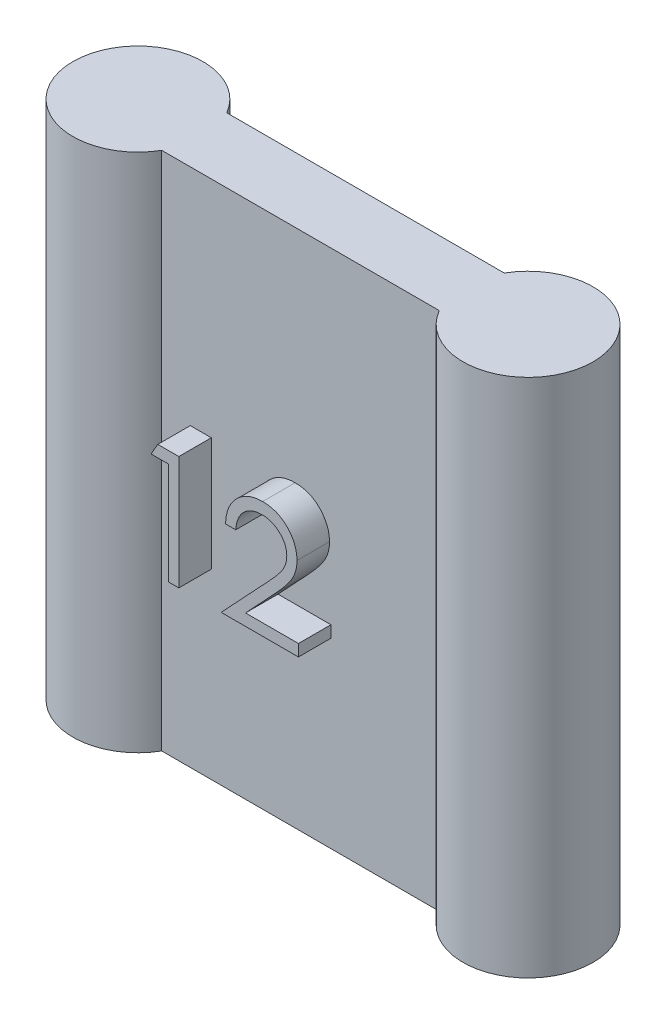
from build123d import *

# Parameters (mm, degrees)
SKETCH1_W           = 12
SKETCH1_H           = 16
BOSS_EXTRUDE1_DEPTH = 2
SKETCH4_R           = 2
BOSS_EXTRUDE4_DEPTH = 16
BOSS_EXTRUDE5_DEPTH = 1


with BuildPart() as part:
    # Sketch1 → Boss-Extrude1 (new body)
    with BuildSketch(Plane.XY):
        Rectangle(SKETCH1_W, SKETCH1_H)
    extrude(amount=BOSS_EXTRUDE1_DEPTH)

    # Sketch4 → Boss-Extrude4 (add)
    with BuildSketch(Plane.XZ.offset(8)):
        with Locations((-6, 1)):
            Circle(SKETCH4_R)
        with Locations((6, 1)):
            Circle(SKETCH4_R)
    extrude(amount=-BOSS_EXTRUDE4_DEPTH)

    # Sketch5 → Boss-Extrude5 (add)
    with BuildSketch(Plane.XY.offset(2)):
        Polygon((-3.389443583, 1.106736913), (-2.742308167, 1.106736913), (-2.742308167, -2.393263087), (-3.056410731, -2.393263087), (-3.056410731, 0.747762554), (-3.594872269, 0.747762554), align=None)
        with BuildLine():
            Line((-0.992308167, 0.029813837), (-1.306410731, 0.029813837))
            add(Edge.make_bspline(
                [(-1.306410731, 0.029813837), (-1.304363578, 0.071484724), (-1.300343024, 0.153325239), (-1.281514735, 0.272649145), (-1.254573857, 0.386703944), (-1.216482403, 0.494573858), (-1.169176126, 0.597212665), (-1.112446098, 0.694212681), (-1.045252248, 0.78520387), (-0.969045514, 0.869342713), (-0.886276875, 0.946530284), (-0.796970935, 1.013185526), (-0.703125908, 1.069503198), (-0.605026509, 1.11658444), (-0.501565945, 1.151924286), (-0.393683087, 1.178145925), (-0.280903951, 1.193922271), (-0.204063929, 1.195618057), (-0.164984449, 1.196480503)],
                knots=[0, 0, 0, 0, 0.000125083, 0.00024566, 0.000361805, 0.000476223, 0.000588214, 0.000700404, 0.000812728, 0.00092691, 0.001040529, 0.001151727, 0.001260545, 0.001368429, 0.001477521, 0.001587884, 0.001701119, 0.00181831, 0.00181831, 0.00181831, 0.00181831], degree=3))
            add(Edge.make_bspline(
                [(-0.164984449, 1.196480503), (-0.126606375, 1.195582047), (-0.05119483, 1.193816612), (0.058867184, 1.178655583), (0.163644479, 1.154909991), (0.262932245, 1.121594575), (0.35593831, 1.076810147), (0.443361354, 1.023012609), (0.526242165, 0.960792777), (0.600848949, 0.887538964), (0.669357028, 0.809336579), (0.728459283, 0.725848676), (0.779072447, 0.63961939), (0.821260127, 0.549991188), (0.852316266, 0.45612016), (0.875894474, 0.359372957), (0.889221887, 0.258748146), (0.891267311, 0.190641591), (0.892307218, 0.15601576)],
                knots=[0, 0, 0, 0, 0.000115089, 0.000226145, 0.000332614, 0.000437044, 0.000539592, 0.000641561, 0.000744629, 0.00084975, 0.000954621, 0.001056175, 0.001156101, 0.001254284, 0.001352726, 0.001452208, 0.001552655, 0.001656537, 0.001656537, 0.001656537, 0.001656537], degree=3))
            add(Edge.make_bspline(
                [(0.892307218, 0.15601576), (0.890613955, 0.107267925), (0.887257144, 0.010627711), (0.858542767, -0.131387151), (0.813696256, -0.26898057), (0.759698899, -0.379717873), (0.705226455, -0.468951366), (0.656138947, -0.542420071), (0.598674136, -0.62152554), (0.531995638, -0.706002877), (0.457482766, -0.796513782), (0.374460603, -0.893003578), (0.282337121, -0.994475347), (0.21767862, -1.063780949), (0.184174205, -1.099693375)],
                knots=[0, 0, 0, 0, 0.000146118, 0.000289672, 0.0004329, 0.00057934, 0.000657978, 0.000746456, 0.000844345, 0.000951219, 0.001069268, 0.00119604, 0.001333047, 0.001480391, 0.001480391, 0.001480391, 0.001480391], degree=3))
            Line((0.184174205, -1.099693375), (-0.691526917, -2.034288728))
            Line((-0.691526917, -2.034288728), (0.937179013, -2.034288728))
            Line((0.937179013, -2.034288728), (0.937179013, -2.393263087))
            Line((0.937179013, -2.393263087), (-1.441026116, -2.393263087))
            Line((-1.441026116, -2.393263087), (-0.083654321, -0.944745458))
            add(Edge.make_bspline(
                [(-0.083654321, -0.944745458), (-0.050606434, -0.910247152), (0.012871793, -0.843982965), (0.10265437, -0.747240005), (0.183293358, -0.657490464), (0.255310751, -0.574903916), (0.317144257, -0.498272348), (0.372016488, -0.430077645), (0.415982079, -0.367323194), (0.463697475, -0.29458258), (0.509911457, -0.205770263), (0.549623813, -0.097236574), (0.573838661, 0.014490679), (0.576743497, 0.089992716), (0.578204654, 0.127970888)],
                knots=[0, 0, 0, 0, 0.000143319, 0.000275286, 0.00039593, 0.000505287, 0.000603949, 0.000691331, 0.000767782, 0.00083371, 0.000952247, 0.001067137, 0.001179618, 0.001293462, 0.001293462, 0.001293462, 0.001293462], degree=3))
            add(Edge.make_bspline(
                [(0.578204654, 0.127970888), (0.577568911, 0.151852286), (0.576315985, 0.198917937), (0.565258288, 0.267923696), (0.548547782, 0.334488509), (0.524602524, 0.398817129), (0.492995784, 0.460262781), (0.454522404, 0.518900261), (0.41013234, 0.575589226), (0.358781071, 0.628742524), (0.302369551, 0.67742373), (0.242775302, 0.720547815), (0.179725197, 0.756586926), (0.113485075, 0.786130423), (0.044239606, 0.809305804), (-0.028145139, 0.825364384), (-0.103469156, 0.835446867), (-0.154902651, 0.836811039), (-0.18111025, 0.837506144)],
                knots=[0, 0, 0, 0, 7.16e-05, 0.00014111, 0.00020913, 0.00027724, 0.000346538, 0.000415963, 0.000487357, 0.000562233, 0.000637292, 0.000710646, 0.000782564, 0.000854749, 0.000927915, 0.001001225, 0.001076884, 0.001155488, 0.001155488, 0.001155488, 0.001155488], degree=3))
            add(Edge.make_bspline(
                [(-0.18111025, 0.837506144), (-0.208481083, 0.836791112), (-0.262232879, 0.835386907), (-0.341151912, 0.825564243), (-0.41643769, 0.808618402), (-0.488279593, 0.785441728), (-0.556799178, 0.755983179), (-0.621663222, 0.719291434), (-0.682726112, 0.675507941), (-0.740102635, 0.625867385), (-0.792966614, 0.570599784), (-0.83941349, 0.508989821), (-0.879997504, 0.442162405), (-0.915406738, 0.370297855), (-0.944162428, 0.292744075), (-0.966135578, 0.20977637), (-0.983522425, 0.121754988), (-0.989330945, 0.060969904), (-0.992308167, 0.029813837)],
                knots=[0, 0, 0, 0, 8.2106e-05, 0.000161243, 0.000238127, 0.000313291, 0.000387401, 0.000461495, 0.000536397, 0.000612445, 0.000688819, 0.000765383, 0.000843422, 0.000923066, 0.001005373, 0.001091093, 0.001180334, 0.001274175, 0.001274175, 0.001274175, 0.001274175], degree=3))
        make_face()
    extrude(amount=BOSS_EXTRUDE5_DEPTH)


solid = part.part
